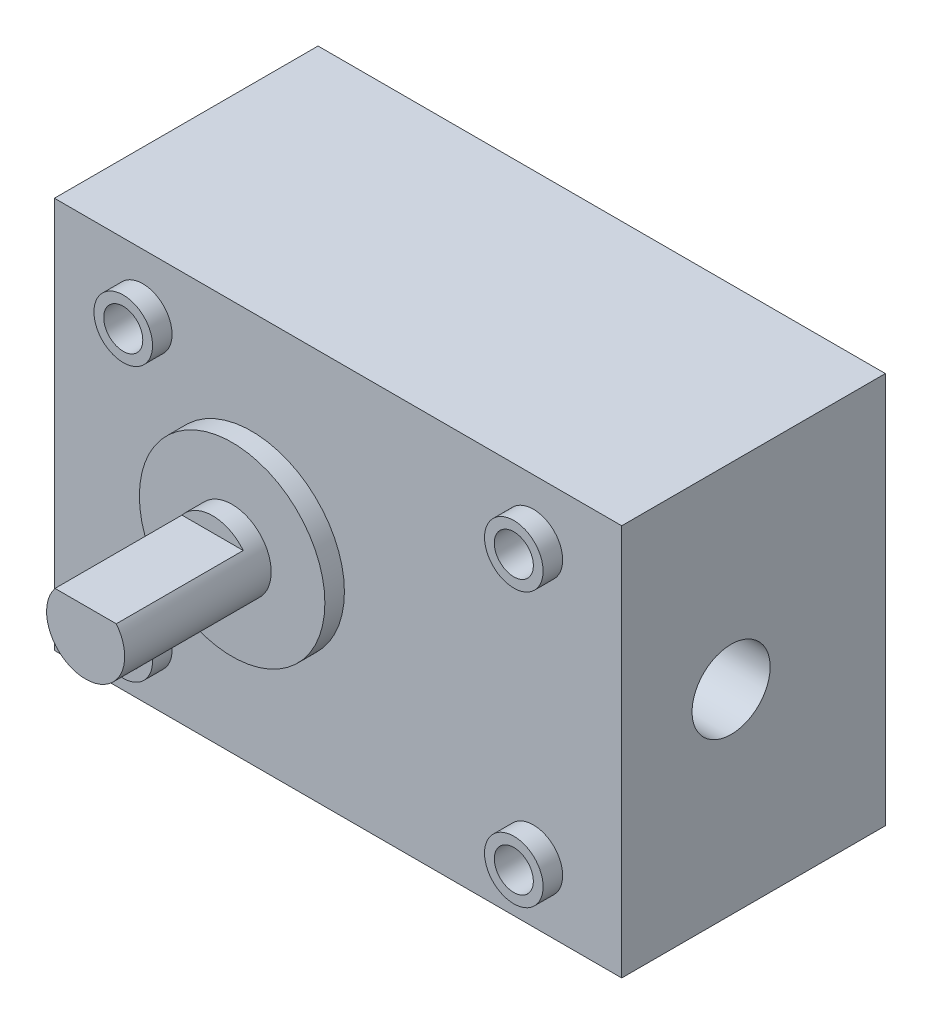
from build123d import *

# Parameters (mm, degrees)
SKETCH1_W           = 58.1
SKETCH1_H           = 40.11
BOSS_EXTRUDE1_DEPTH = 27
SKETCH2_R           = 9.5
BOSS_EXTRUDE2_DEPTH = 2
SKETCH3_R           = 4
BOSS_EXTRUDE3_DEPTH = 15
SKETCH4_W           = 6.276876118
SKETCH4_H           = 1.998885949
CUT_EXTRUDE1_DEPTH  = 13
SKETCH5_R           = 3
BOSS_EXTRUDE4_DEPTH = 2
SKETCH6_R           = 2
CUT_EXTRUDE2_DEPTH  = 8
SKETCH7_R           = 4
CUT_EXTRUDE3_DEPTH  = 25.4


with BuildPart() as part:
    # Sketch1 → Boss-Extrude1 (new body)
    with BuildSketch(Plane.XY):
        with Locations((29.05, 20.055)):
            Rectangle(SKETCH1_W, SKETCH1_H)
    extrude(amount=BOSS_EXTRUDE1_DEPTH)

    # Sketch2 → Boss-Extrude2 (add)
    with BuildSketch(Plane.XY.offset(27)):
        with Locations((20.2, 20.055)):
            Circle(SKETCH2_R)
    extrude(amount=BOSS_EXTRUDE2_DEPTH)

    # Sketch3 → Boss-Extrude3 (add)
    with BuildSketch(Plane.XY.offset(29)):
        with Locations((20.2, 20.055)):
            Circle(SKETCH3_R)
    extrude(amount=BOSS_EXTRUDE3_DEPTH)

    # Sketch4 → Cut-Extrude1 (cut)
    with BuildSketch(Plane.XY.offset(44)):
        with Locations((20.2, 23.534403972)):
            Rectangle(SKETCH4_W, SKETCH4_H)
    extrude(amount=-CUT_EXTRUDE1_DEPTH, mode=Mode.SUBTRACT)

    # Sketch5 → Boss-Extrude4 (add)
    with BuildSketch(Plane.XY.offset(27)):
        with Locations((9.05, 34.055)):
            Circle(SKETCH5_R)
        with Locations((49.05, 34.055)):
            Circle(SKETCH5_R)
        with Locations((49.05, 6.055)):
            Circle(SKETCH5_R)
        with Locations((9.05, 6.055)):
            Circle(SKETCH5_R)
    extrude(amount=BOSS_EXTRUDE4_DEPTH)

    # Sketch6 → Cut-Extrude2 (cut)
    with BuildSketch(Plane.XY.offset(29)):
        with Locations((9.05, 34.055)):
            Circle(SKETCH6_R)
        with Locations((49.05, 34.055)):
            Circle(SKETCH6_R)
        with Locations((49.05, 6.055)):
            Circle(SKETCH6_R)
        with Locations((9.05, 6.055)):
            Circle(SKETCH6_R)
    extrude(amount=-CUT_EXTRUDE2_DEPTH, mode=Mode.SUBTRACT)

    # Sketch7 → Cut-Extrude3 (cut)
    with BuildSketch(Plane(origin=(58.1, 0, 0), x_dir=(0, 0, -1), z_dir=(1, 0, 0))):
        with Locations((-15.797911108, 20)):
            Circle(SKETCH7_R)
    extrude(amount=-CUT_EXTRUDE3_DEPTH, mode=Mode.SUBTRACT)


solid = part.part
